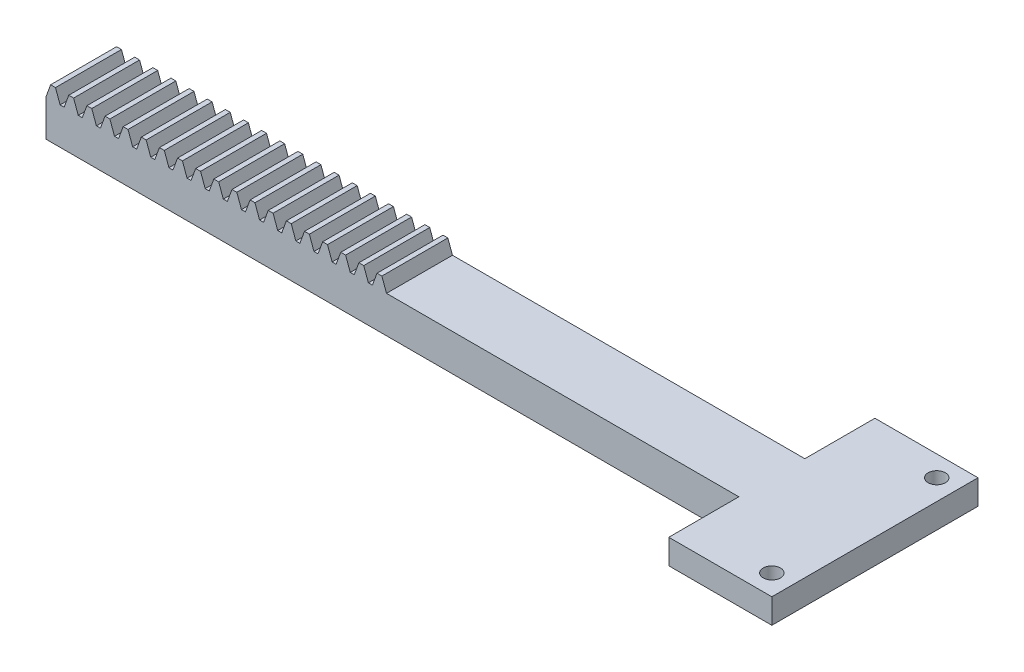
from build123d import *

# Parameters (mm, degrees)
BOSS_EXTRU_1_DEPTH      = 8
ESQUISSE3_W             = 25
ESQUISSE3_H             = 3
BOSS_EXTRU_3_DEPTH      = 12.5
ESQUISSE4_R             = 1.05
ENL_V_MAT_EXTRU_1_DEPTH = 10
ESQUISSE7_W             = 13.702754964
ESQUISSE7_H             = 7.283651796
ENL_V_MAT_EXTRU_2_DEPTH = 55


with BuildPart() as part:
    # Esquisse1 → Boss.-Extru.1 (new body)
    with BuildSketch(Plane.XY.offset(2)):
        Polygon((55.971983753, 0), (140, 0), (140, 4.46), (139.050191247, 4.46), (138.489677086, 6), (137.899678914, 6), (137.339164753, 4.46), (136.851078247, 4.46), (136.290564086, 6), (135.700565914, 6), (135.140051753, 4.46), (134.651965247, 4.46), (134.091451086, 6), (133.501452914, 6), (132.940938753, 4.46), (132.452852247, 4.46), (131.892338086, 6), (131.302339914, 6), (130.741825753, 4.46), (130.253739247, 4.46), (129.693225086, 6), (129.103226914, 6), (128.542712753, 4.46), (128.054626247, 4.46), (127.494112086, 6), (126.904113914, 6), (126.343599753, 4.46), (125.855513247, 4.46), (125.294999086, 6), (124.705000914, 6), (124.144486753, 4.46), (123.656400247, 4.46), (123.095886086, 6), (122.505887914, 6), (121.945373753, 4.46), (121.457287247, 4.46), (120.896773086, 6), (120.306774914, 6), (119.746260753, 4.46), (119.258174247, 4.46), (118.697660086, 6), (118.107661914, 6), (117.547147753, 4.46), (117.059061247, 4.46), (116.498547086, 6), (115.908548914, 6), (115.348034753, 4.46), (114.859948247, 4.46), (114.299434086, 6), (113.709435914, 6), (113.148921753, 4.46), (112.660835247, 4.46), (112.100321086, 6), (111.510322914, 6), (110.949808753, 4.46), (110.461722247, 4.46), (109.901208086, 6), (109.311209914, 6), (108.750695753, 4.46), (108.262609247, 4.46), (107.702095086, 6), (107.112096914, 6), (106.551582753, 4.46), (106.063496247, 4.46), (105.502982086, 6), (104.912983914, 6), (104.352469753, 4.46), (103.864383247, 4.46), (103.303869086, 6), (102.713870914, 6), (102.153356753, 4.46), (101.665270247, 4.46), (101.104756086, 6), (100.514757914, 6), (99.954243753, 4.46), (99.466157247, 4.46), (98.905643086, 6), (98.315644914, 6), (97.755130753, 4.46), (97.267044247, 4.46), (96.706530086, 6), (96.116531914, 6), (95.556017753, 4.46), (95.067931247, 4.46), (94.507417086, 6), (93.917418914, 6), (93.356904753, 4.46), (92.868818247, 4.46), (92.308304086, 6), (91.718305914, 6), (91.157791753, 4.46), (90.669705247, 4.46), (90.109191086, 6), (89.519192914, 6), (88.958678753, 4.46), (88.470592247, 4.46), (87.910078086, 6), (87.320079914, 6), (86.759565753, 4.46), (86.271479247, 4.46), (85.710965086, 6), (85.120966914, 6), (84.560452753, 4.46), (84.072366247, 4.46), (83.511852086, 6), (82.921853914, 6), (82.361339753, 4.46), (81.873253247, 4.46), (81.312739086, 6), (80.722740914, 6), (80.162226753, 4.46), (79.674140247, 4.46), (79.113626086, 6), (78.523627914, 6), (77.963113753, 4.46), (77.475027247, 4.46), (76.914513086, 6), (76.324514914, 6), (75.764000753, 4.46), (75.275914247, 4.46), (74.715400086, 6), (74.125401914, 6), (73.564887753, 4.46), (73.076801247, 4.46), (72.516287086, 6), (71.926288914, 6), (71.365774753, 4.46), (70.877688247, 4.46), (70.317174086, 6), (69.727175914, 6), (69.166661753, 4.46), (68.678575247, 4.46), (68.118061086, 6), (67.528062914, 6), (66.967548753, 4.46), (66.479462247, 4.46), (65.918948086, 6), (65.328949914, 6), (64.768435753, 4.46), (64.280349247, 4.46), (63.719835086, 6), (63.129836914, 6), (62.569322753, 4.46), (62.081236247, 4.46), (61.520722086, 6), (60.930723914, 6), (60.370209753, 4.46), (59.882123247, 4.46), (59.321609086, 6), (58.731610914, 6), (58.171096753, 4.46), (57.683010247, 4.46), (57.122496086, 6), (56.532497914, 6), (55.971983753, 4.46), align=None)
    extrude(amount=-BOSS_EXTRU_1_DEPTH)

    # Esquisse3 → Boss.-Extru.3 (add)
    with BuildSketch(Plane(origin=(140, 0, 0), x_dir=(0, 0, -1), z_dir=(1, 0, 0))):
        with Locations((2, 2.96)):
            Rectangle(ESQUISSE3_W, ESQUISSE3_H)
    extrude(amount=BOSS_EXTRU_3_DEPTH)

    # Esquisse4 → Enlèv. mat.-Extru.1 (cut)
    with BuildSketch(Plane(origin=(0, 4.46, 0), x_dir=(1, 0, 0), z_dir=(0, 1, 0))):
        with Locations((150, -8)):
            Circle(ESQUISSE4_R)
        with Locations((150, 12)):
            Circle(ESQUISSE4_R)
    extrude(amount=-ENL_V_MAT_EXTRU_1_DEPTH, mode=Mode.SUBTRACT)

    # Esquisse7 → Enlèv. mat.-Extru.2 (cut)
    with BuildSketch(Plane(origin=(152.5, 0, 0), x_dir=(0, 0, -1), z_dir=(1, 0, 0))):
        with Locations((2.202713729, 8.101825898)):
            Rectangle(ESQUISSE7_W, ESQUISSE7_H)
    extrude(amount=-ENL_V_MAT_EXTRU_2_DEPTH, mode=Mode.SUBTRACT)


solid = part.part
